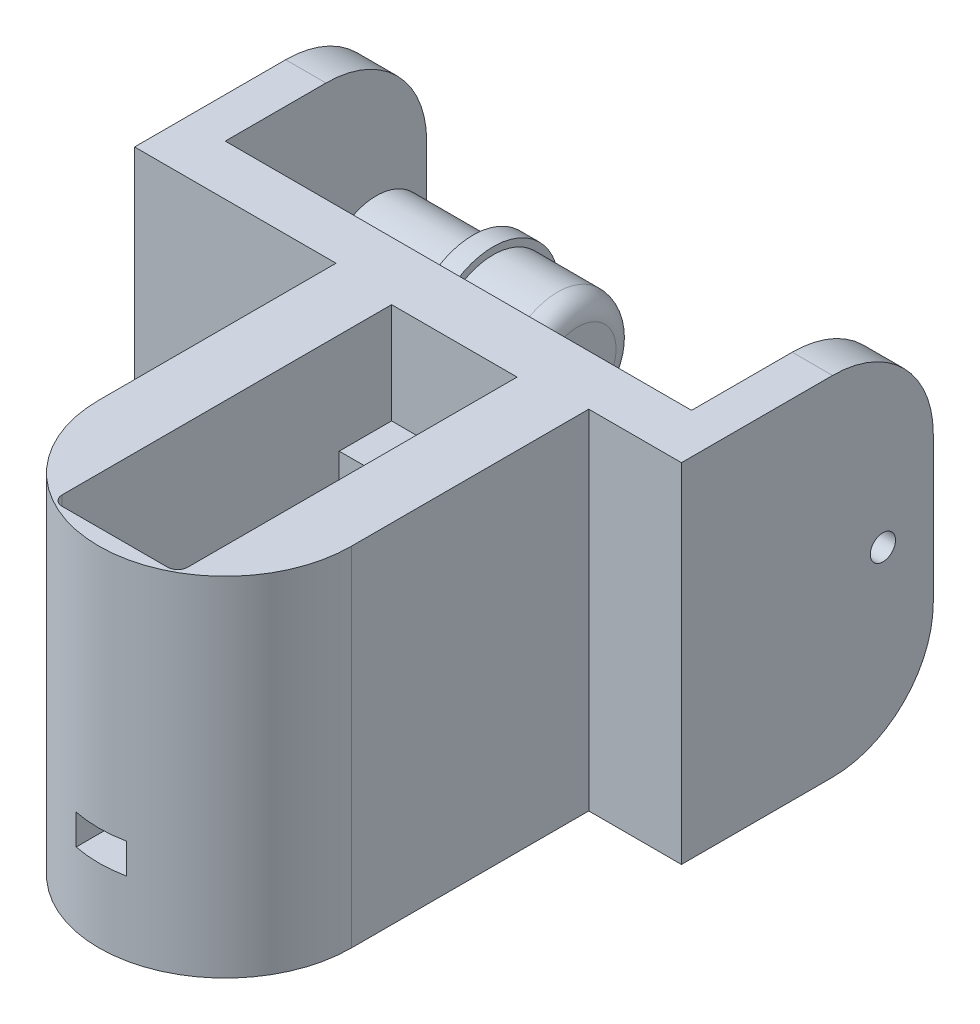
from build123d import *

# Parameters (mm, degrees)
SKETCH4_W                = 12.46
SKETCH4_H                = 17.25
BOSS_EXTRUDE3_DEPTH      = 6
SKETCH8_R                = 12.546781182
SKETCH8_R_2              = 11.15
BOSS_EXTRUDE6_DEPTH      = 7.3
BOSS_EXTRUDE6_DEPTH_BACK = 17.25
BOSS_EXTRUDE4_DEPTH      = 17.25
SKETCH6_R                = 0.5
CUT_EXTRUDE1_DEPTH       = 15
CHAMFER1_SIZE            = 0.5
CHAMFER1_SIZE2           = 0.866025404
SKETCH10_W               = 12.46
SKETCH10_H               = 23.7
CUT_EXTRUDE3_DEPTH       = 17.25
CUT_EXTRUDE4_REACH       = 38.097
SKETCH11_W               = 5
SKETCH11_H               = 3
BOSS_EXTRUDE7_DEPTH      = 7.3
BOSS_EXTRUDE9_DEPTH      = 10
SKETCH20_R               = 11.15
SKETCH20_R_2             = 7.15
BOSS_EXTRUDE11_DEPTH     = 7.3
SKETCH21_R               = 10.15
SKETCH21_R_2             = 7.15
CUT_EXTRUDE7_DEPTH       = 1.3
BOSS_EXTRUDE10_DEPTH     = 34.55
SKETCH18_W               = 20
SKETCH18_H               = 12.438292938
CUT_EXTRUDE5_DEPTH       = 2
SKETCH19_R               = 1.25
CUT_EXTRUDE6_DEPTH       = 53.296781182
CUT_EXTRUDE6_DEPTH_BACK  = 3
FILLET1_R                = 10
SKETCH22_R               = 5.8
BOSS_EXTRUDE12_DEPTH     = 20
FILLET2_R                = 2
SKETCH23_R               = 5.930854157
SKETCH23_R_2             = 5.08
CUT_EXTRUDE8_DEPTH       = 11.6
SKETCH24_R               = 6.5
BOSS_EXTRUDE13_DEPTH     = 2
SKETCH25_R               = 1.25
BOSS_EXTRUDE14_DEPTH     = 2
SKETCH26_W               = 5
SKETCH26_H               = 3
BOSS_EXTRUDE15_DEPTH     = 5


with BuildPart() as part:
    # Sketch4 → Boss-Extrude3 (new body)
    with BuildSketch(Plane.XY):
        with Locations((0, -1.35)):
            Rectangle(SKETCH4_W, SKETCH4_H)
    extrude(amount=BOSS_EXTRUDE3_DEPTH)



with BuildPart() as body_2:
    # Sketch8 → Boss-Extrude6 (new body, two sides)
    with BuildSketch(Plane(origin=(0, -9.975, 0), x_dir=(-1, 0, 0), z_dir=(0, -1, 0))) as boss_extrude6_sk:
        with Locations((0, -23.55)):
            Circle(SKETCH8_R)
        with Locations((0, -23.55)):
            Circle(SKETCH8_R_2, mode=Mode.SUBTRACT)
    extrude(amount=BOSS_EXTRUDE6_DEPTH)
    extrude(boss_extrude6_sk.sketch, amount=-BOSS_EXTRUDE6_DEPTH_BACK)


with BuildPart() as part_1:
    add(part.part)

    add(body_2.part)  # Boss-Extrude4 merges body 2
    # Sketch5 → Boss-Extrude4 (add)
    with BuildSketch(Plane(origin=(0, 7.275, 0), x_dir=(1, 0, 0), z_dir=(0, 1, 0))):
        with BuildLine():
            Line((12.546781182, -23.55), (12.546781182, 0))
            Line((12.546781182, 0), (6.23, 0))
            Line((6.23, 0), (6.23, -29.7))
            Line((6.23, -29.7), (-6.23, -29.7))
            Line((-6.23, -29.7), (-6.23, 0))
            Line((-6.23, 0), (-12.546781182, 0))
            Line((-12.546781182, 0), (-12.546781182, -23.55))
            ThreePointArc((-12.546781182, -23.55), (0, -36.096781182), (12.546781182, -23.55))
        make_face()
    extrude(amount=-BOSS_EXTRUDE4_DEPTH)

    # Sketch6 → Cut-Extrude1 (cut)
    with BuildSketch(Plane(origin=(0, 7.275, 0), x_dir=(1, 0, 0), z_dir=(0, 1, 0))):
        with Locations((0, -3.6)):
            Circle(SKETCH6_R)
        with Locations((0, -32.1)):
            Circle(SKETCH6_R)
    extrude(amount=-CUT_EXTRUDE1_DEPTH, mode=Mode.SUBTRACT)

    # Chamfer1
    chamfer1_edges = [part_1.edges().sort_by_distance(p)[0] for p in [
        (-0.5, 7.275, 3.6),
        (-0.5, 7.275, 32.1),
    ]]
    chamfer1_side = [part_1.faces().sort_by_distance(p)[0] for p in [
        (0, 7.275, 35.657160381),
    ]]
    chamfer(chamfer1_edges, length=CHAMFER1_SIZE, length2=CHAMFER1_SIZE2, reference=chamfer1_side[0])

    # Sketch10 → Cut-Extrude3 (cut)
    with BuildSketch(Plane(origin=(0, 7.275, 0), x_dir=(1, 0, 0), z_dir=(0, 1, 0))):
        with Locations((0, -17.85)):
            Rectangle(SKETCH10_W, SKETCH10_H)
    extrude(amount=-CUT_EXTRUDE3_DEPTH, mode=Mode.SUBTRACT)

    # Sketch11 → Cut-Extrude4 (cut, up to next)
    with BuildSketch(Plane.XY.offset(36.096781182), mode=Mode.PRIVATE) as cut_extrude4_sk1:
        with Locations((0, -8.475)):
            Rectangle(SKETCH11_W, SKETCH11_H)
    cut_extrude4_tool1 = extrude(cut_extrude4_sk1.sketch, amount=-CUT_EXTRUDE4_REACH, mode=Mode.PRIVATE) & part_1.part
    add(cut_extrude4_tool1.solids().sort_by_distance((0, -8.475, 36.096781))[0], mode=Mode.SUBTRACT)

    # Sketch13 → Boss-Extrude7 (add)
    with BuildSketch(Plane.XZ.offset(17.275)):
        with BuildLine():
            Line((-12.546781182, 23.55), (-12.546781182, 0))
            Line((-12.546781182, 0), (12.546781182, 0))
            Line((12.546781182, 0), (12.546781182, 23.55))
            ThreePointArc((12.546781182, 23.55), (0, 11.003218818), (-12.546781182, 23.55))
        make_face()
    extrude(amount=-BOSS_EXTRUDE7_DEPTH)

    # Sketch15 → Boss-Extrude9 (add)
    with BuildSketch(Plane(origin=(0, 7.275, 0), x_dir=(1, 0, 0), z_dir=(0, 1, 0))):
        with BuildLine():
            Line((-12.546781182, 0), (12.546781182, 0))
            Line((12.546781182, 0), (12.546781182, -23.55))
            ThreePointArc((12.546781182, -23.55), (0, -36.096781182), (-12.546781182, -23.55))
            Line((-12.546781182, -23.55), (-12.546781182, 0))
        make_face()
        with BuildLine():
            Line((-6.23, -0.8), (6.23, -0.8))
            Line((6.23, -0.8), (6.23, -33.5))
            ThreePointArc((6.23, -33.5), (5.937106781, -34.207106781), (5.23, -34.5))
            Line((5.23, -34.5), (-5.23, -34.5))
            ThreePointArc((-5.23, -34.5), (-5.937106781, -34.207106781), (-6.23, -33.5))
            Line((-6.23, -33.5), (-6.23, -0.8))
        make_face(mode=Mode.SUBTRACT)
    extrude(amount=BOSS_EXTRUDE9_DEPTH)

    # Sketch20 → Boss-Extrude11 (add)
    with BuildSketch(Plane.XZ.offset(17.275)):
        with Locations((0, 23.55)):
            Circle(SKETCH20_R)
        with Locations((0, 23.55)):
            Circle(SKETCH20_R_2, mode=Mode.SUBTRACT)
    extrude(amount=-BOSS_EXTRUDE11_DEPTH)

    # Sketch21 → Cut-Extrude7 (cut)
    with BuildSketch(Plane.XZ.offset(17.275)):
        with Locations((0, 23.55)):
            Circle(SKETCH21_R)
        with Locations((0, 23.55)):
            Circle(SKETCH21_R_2, mode=Mode.SUBTRACT)
    extrude(amount=-CUT_EXTRUDE7_DEPTH, mode=Mode.SUBTRACT)

    # Sketch17 → Boss-Extrude10 (add)
    with BuildSketch(Plane(origin=(0, 17.275, 0), x_dir=(1, 0, 0), z_dir=(0, 1, 0))):
        Polygon((21.75, 25), (21.75, 0), (-32.546781182, 0), (-32.546781182, 25), (-28.546781182, 25), (-28.546781182, 5), (17.75, 5), (17.75, 25), align=None)
    extrude(amount=-BOSS_EXTRUDE10_DEPTH)

    # Sketch18 → Cut-Extrude5 (cut)
    with BuildSketch(Plane.ZY.offset(-17.75)):
        with Locations((-15, 0)):
            Rectangle(SKETCH18_W, SKETCH18_H)
    extrude(amount=-CUT_EXTRUDE5_DEPTH, mode=Mode.SUBTRACT)

    # Sketch19 → Cut-Extrude6 (cut, two sides)
    with BuildSketch(Plane.ZY.offset(-19.75)) as cut_extrude6_sk:
        with Locations((-20, 0)):
            Circle(SKETCH19_R)
    extrude(amount=CUT_EXTRUDE6_DEPTH, mode=Mode.SUBTRACT)
    extrude(cut_extrude6_sk.sketch, amount=-CUT_EXTRUDE6_DEPTH_BACK, mode=Mode.SUBTRACT)

    # Fillet1
    fillet1_edges = [part_1.edges().sort_by_distance(p)[0] for p in [
        (19.75, 17.275, -25),
        (-30.546781182, 17.275, -25),
        (-30.546781182, -17.275, -25),
        (19.75, -17.275, -25),
    ]]
    fillet(fillet1_edges, radius=FILLET1_R)

    # Sketch22 → Boss-Extrude12 (add)
    with BuildSketch(Plane(origin=(-28.546781182, 0, 0), x_dir=(0, 0, -1), z_dir=(1, 0, 0))):
        with Locations((20, 0)):
            Circle(SKETCH22_R)
    extrude(amount=BOSS_EXTRUDE12_DEPTH)

    # Fillet2
    fillet2_edges = [part_1.edges().sort_by_distance(p)[0] for p in [
        (-8.546781182, 0, -14.2),
    ]]
    fillet(fillet2_edges, radius=FILLET2_R)

    # Sketch23 → Cut-Extrude8 (cut)
    with BuildSketch(Plane(origin=(-28.546781182, 0, 0), x_dir=(0, 0, -1), z_dir=(1, 0, 0))):
        with Locations((20, 0)):
            Circle(SKETCH23_R)
        with Locations((20, 0)):
            Circle(SKETCH23_R_2, mode=Mode.SUBTRACT)
    extrude(amount=CUT_EXTRUDE8_DEPTH, mode=Mode.SUBTRACT)

    # Sketch24 → Boss-Extrude13 (add)
    with BuildSketch(Plane.ZY.offset(16.946781182)):
        with Locations((-20, 0)):
            Circle(SKETCH24_R)
    extrude(amount=BOSS_EXTRUDE13_DEPTH)

    # Sketch25 → Boss-Extrude14 (add)
    with BuildSketch(Plane.ZY.offset(32.546781182)):
        with Locations((-20, 0)):
            Circle(SKETCH25_R)
    extrude(amount=-BOSS_EXTRUDE14_DEPTH)

    # Sketch26 → Boss-Extrude15 (add)
    with BuildSketch(Plane(origin=(-28.546781182, 0, 0), x_dir=(0, 0, -1), z_dir=(1, 0, 0))):
        with Locations((7.5, -8.275)):
            Rectangle(SKETCH26_W, SKETCH26_H)
        with Locations((7.5, -3.759)):
            Rectangle(SKETCH26_W, SKETCH26_H)
    extrude(amount=BOSS_EXTRUDE15_DEPTH)


solid = part_1.part
